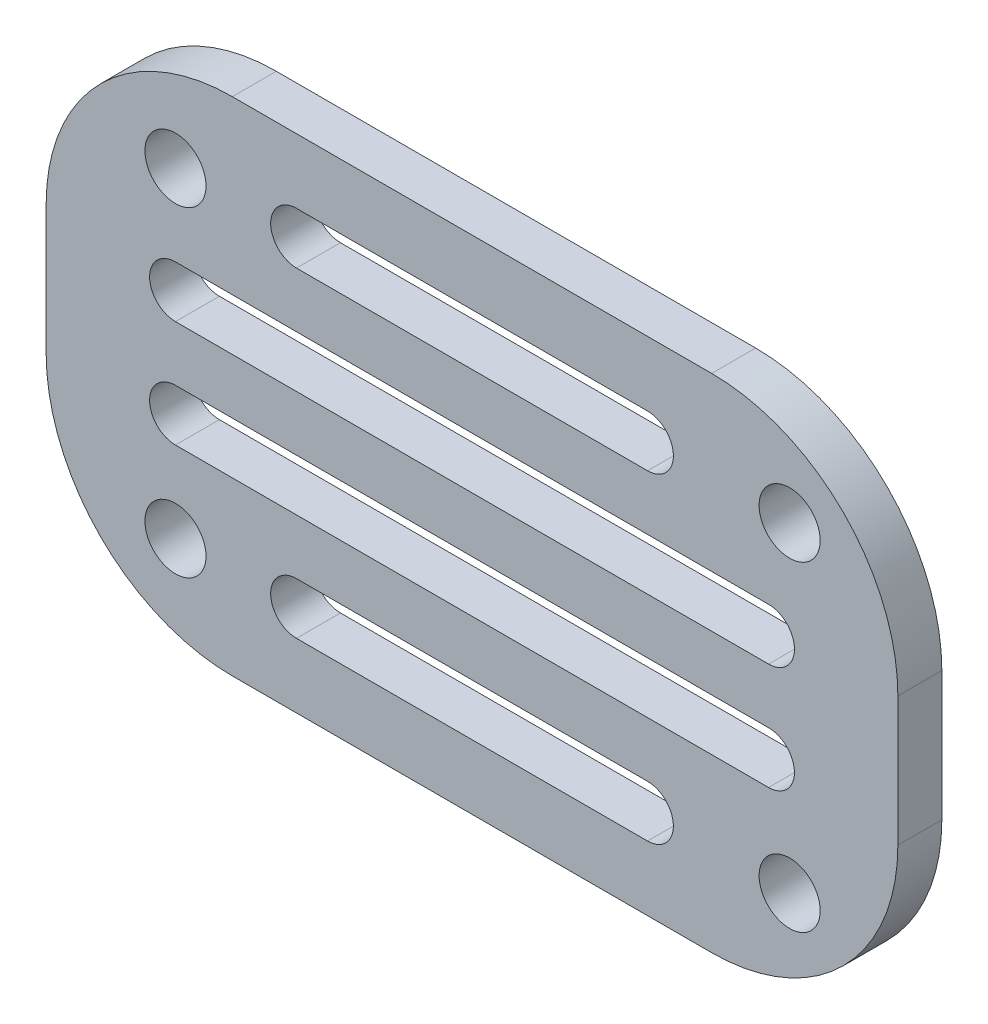
from build123d import *

# Parameters (mm, degrees)
SKETCH1_R           = 1.5
BOSS_EXTRUDE1_DEPTH = 2.159
CUT_EXTRUDE1_DEPTH  = 3.159


with BuildPart() as part:
    # Sketch1 → Boss-Extrude1 (new body)
    with BuildSketch(Plane.XY):
        with BuildLine():
            Line((-9.906, 12.319), (13.634725801, 12.319))
            ThreePointArc((13.634725801, 12.319), (20.100510208, 9.640784407), (22.778725801, 3.175))
            Line((22.778725801, 3.175), (22.778725801, -3.175))
            ThreePointArc((22.778725801, -3.175), (20.100510208, -9.640784407), (13.634725801, -12.319))
            Line((13.634725801, -12.319), (-9.906, -12.319))
            ThreePointArc((-9.906, -12.319), (-16.371784407, -9.640784407), (-19.05, -3.175))
            Line((-19.05, -3.175), (-19.05, 3.175))
            ThreePointArc((-19.05, 3.175), (-16.371784407, 9.640784407), (-9.906, 12.319))
        make_face()
        with Locations((-12.7, 7.874)):
            Circle(SKETCH1_R, mode=Mode.SUBTRACT)
        with Locations((-12.7, -7.874)):
            Circle(SKETCH1_R, mode=Mode.SUBTRACT)
        with Locations((17.4625, 7.874)):
            Circle(SKETCH1_R, mode=Mode.SUBTRACT)
        with Locations((17.4625, -7.874)):
            Circle(SKETCH1_R, mode=Mode.SUBTRACT)
    extrude(amount=BOSS_EXTRUDE1_DEPTH)

    # Sketch4 → Cut-Extrude1 (cut, through all)
    with BuildSketch(Plane.XY.offset(2.159)):
        with BuildLine():
            Line((-6.755, 9.144), (10.483725801, 9.144))
            ThreePointArc((10.483725801, 9.144), (11.753725801, 7.874), (10.483725801, 6.604))
            Line((10.483725801, 6.604), (-6.755, 6.604))
            ThreePointArc((-6.755, 6.604), (-8.025, 7.874), (-6.755, 9.144))
        make_face()
        with BuildLine():
            Line((-12.7, 3.894666667), (16.428725801, 3.894666667))
            ThreePointArc((16.428725801, 3.894666667), (17.698725801, 2.624666667), (16.428725801, 1.354666667))
            Line((16.428725801, 1.354666667), (-12.7, 1.354666667))
            ThreePointArc((-12.7, 1.354666667), (-13.97, 2.624666667), (-12.7, 3.894666667))
        make_face()
        with BuildLine():
            Line((-12.7, -1.354666667), (16.428725801, -1.354666667))
            ThreePointArc((16.428725801, -1.354666667), (17.698725801, -2.624666667), (16.428725801, -3.894666667))
            Line((16.428725801, -3.894666667), (-12.7, -3.894666667))
            ThreePointArc((-12.7, -3.894666667), (-13.97, -2.624666667), (-12.7, -1.354666667))
        make_face()
        with BuildLine():
            Line((-6.755, -6.604), (10.483725801, -6.604))
            ThreePointArc((10.483725801, -6.604), (11.753725801, -7.874), (10.483725801, -9.144))
            Line((10.483725801, -9.144), (-6.755, -9.144))
            ThreePointArc((-6.755, -9.144), (-8.025, -7.874), (-6.755, -6.604))
        make_face()
    extrude(amount=-CUT_EXTRUDE1_DEPTH, mode=Mode.SUBTRACT)


solid = part.part
